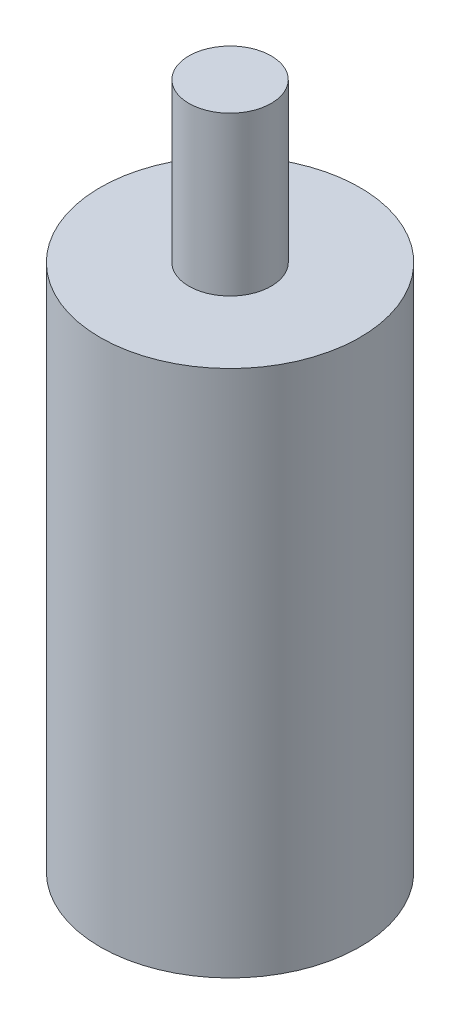
from build123d import *

# Parameters (mm, degrees)
SKETCH1_R           = 0.78
BOSS_EXTRUDE2_DEPTH = 3
SKETCH1_5_R         = 2.46136009
SKETCH1_5_R_2       = 0.78
BOSS_EXTRUDE3_DEPTH = 10


with BuildPart() as part:
    # Sketch1 → Boss-Extrude2 (new body)
    with BuildSketch(Plane(origin=(0, 0, 0), x_dir=(1, 0, 0), z_dir=(0, 1, 0))):
        with Locations((2.051993992, 1.359269712)):
            Circle(SKETCH1_R)
    extrude(amount=BOSS_EXTRUDE2_DEPTH)


with BuildPart() as body_2:
    # Sketch1_5 → Boss-Extrude3 (new body)
    with BuildSketch(Plane(origin=(0, 0, 0), x_dir=(1, 0, 0), z_dir=(0, 1, 0))):
        with Locations((2.051993992, 1.359269712)):
            Circle(SKETCH1_5_R)
        with Locations((2.051993992, 1.359269712)):
            Circle(SKETCH1_5_R_2, mode=Mode.SUBTRACT)
    extrude(amount=-BOSS_EXTRUDE3_DEPTH)


solid = Compound([part.part, body_2.part])
